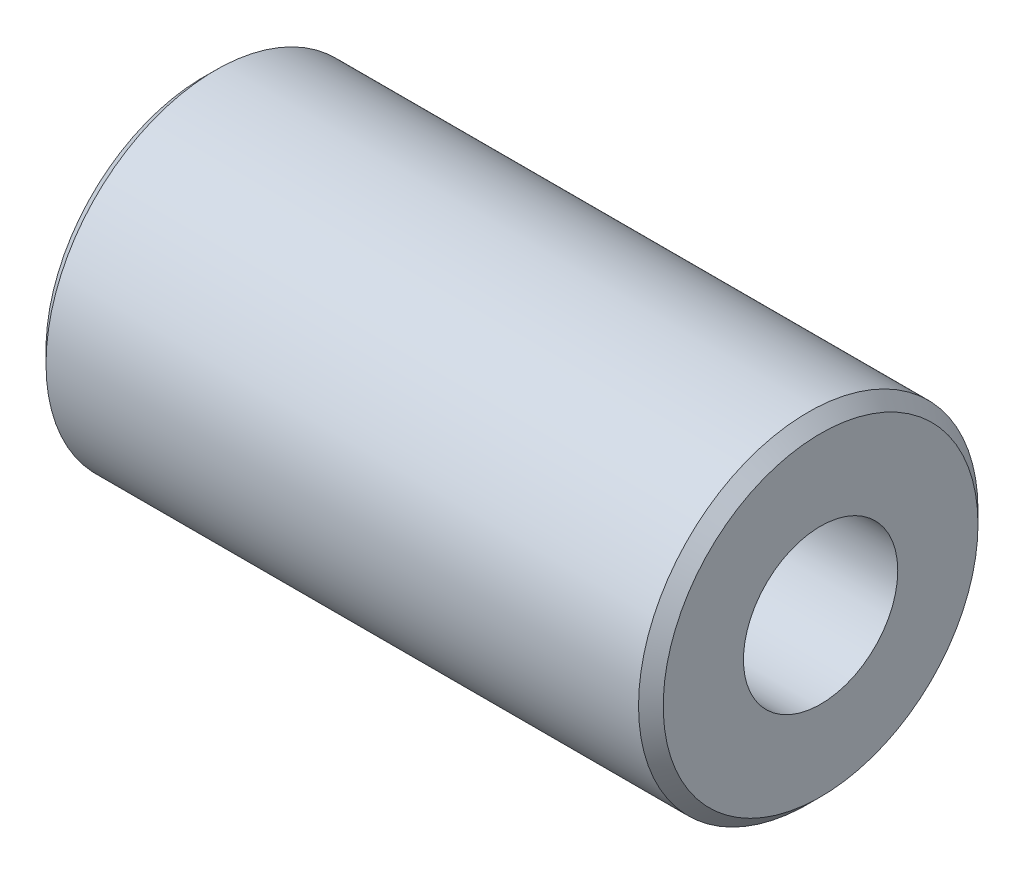
from build123d import *

# Parameters (mm, degrees)
SKETCH1_R                 = 2.75
BOSS_EXTRUDE1_DEPTH       = 5
CHAMFER1_SIZE             = 0.2
M3X0_5_TAPPED_HOLE1_D     = 2.5
M3X0_5_TAPPED_HOLE1_DEPTH = 7.5
M3X0_5_TAPPED_HOLE1_TIP   = 0.751075774


with BuildPart() as part:
    # Sketch1 → Boss-Extrude1 (new body, symmetric)
    with BuildSketch(Plane(origin=(0, 0, 0), x_dir=(0, -1, 0), z_dir=(1, 0, 0))):
        Circle(SKETCH1_R)
    extrude(amount=BOSS_EXTRUDE1_DEPTH, both=True)

    # Chamfer1
    chamfer1_edges = [part.edges().sort_by_distance(p)[0] for p in [
        (-5, 2.75, 0),
        (5, 2.75, 0),
    ]]
    chamfer(chamfer1_edges, length=CHAMFER1_SIZE)

    # M3x0.5 Tapped Hole1
    with Locations(Plane(origin=(5, 0, 0), x_dir=(0, 0, -1), z_dir=(1, 0, 0))):
        with Locations((0, 0)):
            Hole(M3X0_5_TAPPED_HOLE1_D / 2, depth=M3X0_5_TAPPED_HOLE1_DEPTH)
            with Locations((0, 0, -(M3X0_5_TAPPED_HOLE1_DEPTH + M3X0_5_TAPPED_HOLE1_TIP / 2))):  # 118° drill point
                Cone(0, M3X0_5_TAPPED_HOLE1_D / 2, M3X0_5_TAPPED_HOLE1_TIP, mode=Mode.SUBTRACT)


solid = part.part
